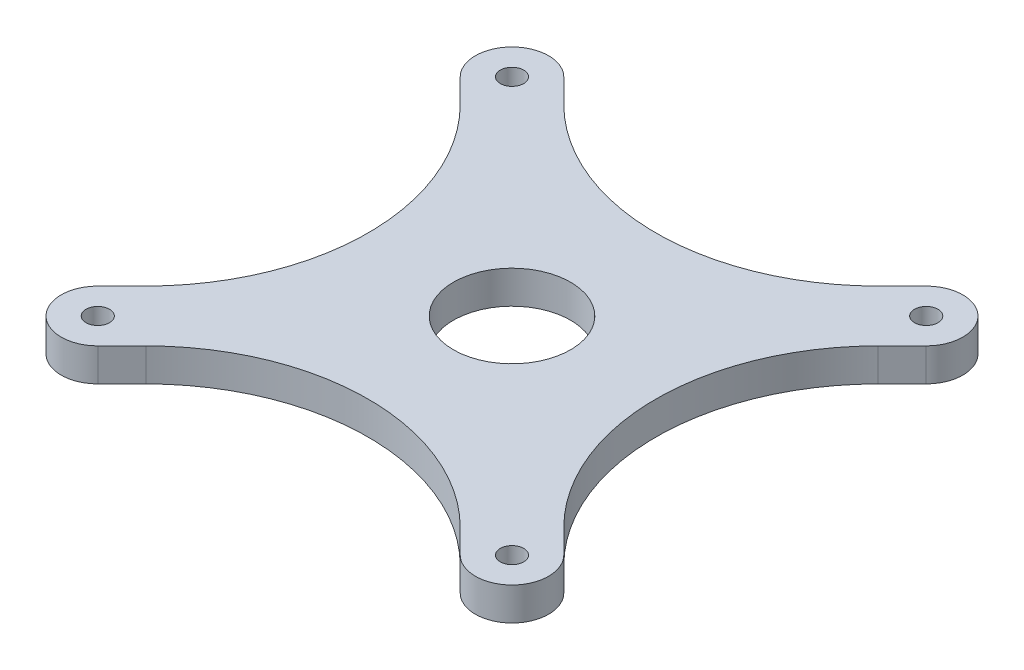
from build123d import *

# Parameters (mm, degrees)
SKETCH_1_W          = 70
SKETCH_1_H          = 70
EXTRUDE_1_DEPTH     = 5
SKETCH_2_R          = 8
CUT_EXTRUDE_1_DEPTH = 2.5
CUT_EXTRUDE_2_REACH = 4.5
SKETCH_3_R          = 6.5
SKETCH_4_W          = 70
SKETCH_4_H          = 70
SKETCH_4_R          = 10
CUT_EXTRUDE_3_DEPTH = 0.5
CUT_EXTRUDE_4_REACH = 7
SKETCH_5_R          = 1.6
CUT_EXTRUDE_6_REACH = 6.5
CUT_EXTRUDE_7_REACH = 6.5
FILLET_1_R          = 10
SKETCH_8_R          = 10
CUT_EXTRUDE_8_DEPTH = 0.5
EXTRUDE_2_DEPTH     = 4.5
CUT_EXTRUDE_9_REACH = 4
SKETCH_10_R         = 8
SKETCH_10_R_2       = 6.5


with BuildPart() as part:
    # 草图1 → 凸台-拉伸1 (new body)
    with BuildSketch(Plane(origin=(0, 0, 0), x_dir=(1, 0, 0), z_dir=(0, 1, 0))):
        Rectangle(SKETCH_1_W, SKETCH_1_H)
    extrude(amount=EXTRUDE_1_DEPTH)

    # 草图2 → 切除-拉伸1 (cut)
    with BuildSketch(Plane(origin=(0, 5, 0), x_dir=(1, 0, 0), z_dir=(0, 1, 0))):
        Circle(SKETCH_2_R)
    extrude(amount=-CUT_EXTRUDE_1_DEPTH, mode=Mode.SUBTRACT)

    # 草图3 → 切除-拉伸2 (cut, up to next)
    with BuildSketch(Plane(origin=(0, 2.5, 0), x_dir=(1, 0, 0), z_dir=(0, 1, 0)), mode=Mode.PRIVATE) as cut_extrude_2_sk1:
        Circle(SKETCH_3_R)
    cut_extrude_2_tool1 = extrude(cut_extrude_2_sk1.sketch, amount=-CUT_EXTRUDE_2_REACH, mode=Mode.PRIVATE) & part.part
    add(cut_extrude_2_tool1.solids().sort_by_distance((0, 2.5, 0))[0], mode=Mode.SUBTRACT)

    # 草图4 → 切除-拉伸3 (cut)
    with BuildSketch(Plane.XZ):
        Rectangle(SKETCH_4_W, SKETCH_4_H)
        Circle(SKETCH_4_R, mode=Mode.SUBTRACT)
    extrude(amount=-CUT_EXTRUDE_3_DEPTH, mode=Mode.SUBTRACT)

    # 草图5 → 切除-拉伸4 (cut, up to next)
    with BuildSketch(Plane(origin=(0, 5, 0), x_dir=(1, 0, 0), z_dir=(0, 1, 0)), mode=Mode.PRIVATE) as cut_extrude_4_sk1:
        with Locations((28.284271247, -28.284271247)):
            Circle(SKETCH_5_R)
    cut_extrude_4_tool1 = extrude(cut_extrude_4_sk1.sketch, amount=-CUT_EXTRUDE_4_REACH, mode=Mode.PRIVATE) & part.part
    add(cut_extrude_4_tool1.solids().sort_by_distance((28.284271, 5, 28.284271))[0], mode=Mode.SUBTRACT)
    # 草图5 → 切除-拉伸4 (cut, up to next)
    with BuildSketch(Plane(origin=(0, 5, 0), x_dir=(1, 0, 0), z_dir=(0, 1, 0)), mode=Mode.PRIVATE) as cut_extrude_4_sk2:
        with Locations((-28.284271247, -28.284271247)):
            Circle(SKETCH_5_R)
    cut_extrude_4_tool2 = extrude(cut_extrude_4_sk2.sketch, amount=-CUT_EXTRUDE_4_REACH, mode=Mode.PRIVATE) & part.part
    add(cut_extrude_4_tool2.solids().sort_by_distance((-28.284271, 5, 28.284271))[0], mode=Mode.SUBTRACT)
    # 草图5 → 切除-拉伸4 (cut, up to next)
    with BuildSketch(Plane(origin=(0, 5, 0), x_dir=(1, 0, 0), z_dir=(0, 1, 0)), mode=Mode.PRIVATE) as cut_extrude_4_sk3:
        with Locations((-28.284271247, 28.284271247)):
            Circle(SKETCH_5_R)
    cut_extrude_4_tool3 = extrude(cut_extrude_4_sk3.sketch, amount=-CUT_EXTRUDE_4_REACH, mode=Mode.PRIVATE) & part.part
    add(cut_extrude_4_tool3.solids().sort_by_distance((-28.284271, 5, -28.284271))[0], mode=Mode.SUBTRACT)
    # 草图5 → 切除-拉伸4 (cut, up to next)
    with BuildSketch(Plane(origin=(0, 5, 0), x_dir=(1, 0, 0), z_dir=(0, 1, 0)), mode=Mode.PRIVATE) as cut_extrude_4_sk4:
        with Locations((28.284271247, 28.284271247)):
            Circle(SKETCH_5_R)
    cut_extrude_4_tool4 = extrude(cut_extrude_4_sk4.sketch, amount=-CUT_EXTRUDE_4_REACH, mode=Mode.PRIVATE) & part.part
    add(cut_extrude_4_tool4.solids().sort_by_distance((28.284271, 5, -28.284271))[0], mode=Mode.SUBTRACT)

    # 草图6 → 切除-拉伸6 (cut, up to next)
    with BuildSketch(Plane.XZ.offset(-0.5), mode=Mode.PRIVATE) as cut_extrude_6_sk1:
        with BuildLine():
            Line((27.928932188, 35), (4.565391967, 11.636459779))
            ThreePointArc((4.565391967, 11.636459779), (0, 12.5), (-4.565391967, 11.636459779))
            Line((-4.565391967, 11.636459779), (-27.928932188, 35))
            Line((-27.928932188, 35), (27.928932188, 35))
        make_face()
    cut_extrude_6_tool1 = extrude(cut_extrude_6_sk1.sketch, amount=-CUT_EXTRUDE_6_REACH, mode=Mode.PRIVATE) & part.part
    add(cut_extrude_6_tool1.solids().sort_by_distance((0, 0.5, 26.217235))[0], mode=Mode.SUBTRACT)
    # 草图6 → 切除-拉伸6 (cut, up to next)
    with BuildSketch(Plane.XZ.offset(-0.5), mode=Mode.PRIVATE) as cut_extrude_6_sk2:
        with BuildLine():
            Line((35, -27.928932188), (11.636459779, -4.565391967))
            ThreePointArc((11.636459779, -4.565391967), (12.5, 0), (11.636459779, 4.565391967))
            Line((11.636459779, 4.565391967), (35, 27.928932188))
            Line((35, 27.928932188), (35, -27.928932188))
        make_face()
    cut_extrude_6_tool2 = extrude(cut_extrude_6_sk2.sketch, amount=-CUT_EXTRUDE_6_REACH, mode=Mode.PRIVATE) & part.part
    add(cut_extrude_6_tool2.solids().sort_by_distance((26.217235, 0.5, 0))[0], mode=Mode.SUBTRACT)
    # 草图6 → 切除-拉伸6 (cut, up to next)
    with BuildSketch(Plane.XZ.offset(-0.5), mode=Mode.PRIVATE) as cut_extrude_6_sk3:
        with BuildLine():
            Line((-27.928932188, -35), (-4.565391967, -11.636459779))
            ThreePointArc((-4.565391967, -11.636459779), (0, -12.5), (4.565391967, -11.636459779))
            Line((4.565391967, -11.636459779), (27.928932188, -35))
            Line((27.928932188, -35), (-27.928932188, -35))
        make_face()
    cut_extrude_6_tool3 = extrude(cut_extrude_6_sk3.sketch, amount=-CUT_EXTRUDE_6_REACH, mode=Mode.PRIVATE) & part.part
    add(cut_extrude_6_tool3.solids().sort_by_distance((0, 0.5, -26.217235))[0], mode=Mode.SUBTRACT)
    # 草图6 → 切除-拉伸6 (cut, up to next)
    with BuildSketch(Plane.XZ.offset(-0.5), mode=Mode.PRIVATE) as cut_extrude_6_sk4:
        with BuildLine():
            Line((-35, 27.928932188), (-11.636459779, 4.565391967))
            ThreePointArc((-11.636459779, 4.565391967), (-12.5, 0), (-11.636459779, -4.565391967))
            Line((-11.636459779, -4.565391967), (-35, -27.928932188))
            Line((-35, -27.928932188), (-35, 27.928932188))
        make_face()
    cut_extrude_6_tool4 = extrude(cut_extrude_6_sk4.sketch, amount=-CUT_EXTRUDE_6_REACH, mode=Mode.PRIVATE) & part.part
    add(cut_extrude_6_tool4.solids().sort_by_distance((-26.217235, 0.5, 0))[0], mode=Mode.SUBTRACT)

    # 草图7 → 切除-拉伸7 (cut, up to next)
    with BuildSketch(Plane.XZ.offset(-0.5), mode=Mode.PRIVATE) as cut_extrude_7_sk1:
        with BuildLine():
            Line((35, 27.928932188), (35, 35))
            Line((35, 35), (27.928932188, 35))
            Line((27.928932188, 35), (24.748737342, 31.819805153))
            ThreePointArc((24.748737342, 31.819805153), (31.819805153, 31.819805153), (31.819805153, 24.748737342))
            Line((31.819805153, 24.748737342), (35, 27.928932188))
        make_face()
    cut_extrude_7_tool1 = extrude(cut_extrude_7_sk1.sketch, amount=-CUT_EXTRUDE_7_REACH, mode=Mode.PRIVATE) & part.part
    add(cut_extrude_7_tool1.solids().sort_by_distance((32.243136, 0.5, 32.243136))[0], mode=Mode.SUBTRACT)
    # 草图7 → 切除-拉伸7 (cut, up to next)
    with BuildSketch(Plane.XZ.offset(-0.5), mode=Mode.PRIVATE) as cut_extrude_7_sk2:
        with BuildLine():
            Line((27.928932188, -35), (24.748737342, -31.819805153))
            ThreePointArc((24.748737342, -31.819805153), (31.819805153, -31.819805153), (31.819805153, -24.748737342))
            Line((31.819805153, -24.748737342), (35, -27.928932188))
            Line((35, -27.928932188), (35, -35))
            Line((35, -35), (27.928932188, -35))
        make_face()
    cut_extrude_7_tool2 = extrude(cut_extrude_7_sk2.sketch, amount=-CUT_EXTRUDE_7_REACH, mode=Mode.PRIVATE) & part.part
    add(cut_extrude_7_tool2.solids().sort_by_distance((32.243136, 0.5, -32.243136))[0], mode=Mode.SUBTRACT)
    # 草图7 → 切除-拉伸7 (cut, up to next)
    with BuildSketch(Plane.XZ.offset(-0.5), mode=Mode.PRIVATE) as cut_extrude_7_sk3:
        with BuildLine():
            Line((-35, -27.928932188), (-31.819805153, -24.748737342))
            ThreePointArc((-31.819805153, -24.748737342), (-31.819805153, -31.819805153), (-24.748737342, -31.819805153))
            Line((-24.748737342, -31.819805153), (-27.928932188, -35))
            Line((-27.928932188, -35), (-35, -35))
            Line((-35, -35), (-35, -27.928932188))
        make_face()
    cut_extrude_7_tool3 = extrude(cut_extrude_7_sk3.sketch, amount=-CUT_EXTRUDE_7_REACH, mode=Mode.PRIVATE) & part.part
    add(cut_extrude_7_tool3.solids().sort_by_distance((-32.243136, 0.5, -32.243136))[0], mode=Mode.SUBTRACT)
    # 草图7 → 切除-拉伸7 (cut, up to next)
    with BuildSketch(Plane.XZ.offset(-0.5), mode=Mode.PRIVATE) as cut_extrude_7_sk4:
        with BuildLine():
            Line((-27.928932188, 35), (-24.748737342, 31.819805153))
            ThreePointArc((-24.748737342, 31.819805153), (-31.819805153, 31.819805153), (-31.819805153, 24.748737342))
            Line((-31.819805153, 24.748737342), (-35, 27.928932188))
            Line((-35, 27.928932188), (-35, 35))
            Line((-35, 35), (-27.928932188, 35))
        make_face()
    cut_extrude_7_tool4 = extrude(cut_extrude_7_sk4.sketch, amount=-CUT_EXTRUDE_7_REACH, mode=Mode.PRIVATE) & part.part
    add(cut_extrude_7_tool4.solids().sort_by_distance((-32.243136, 0.5, 32.243136))[0], mode=Mode.SUBTRACT)

    # 圆角1
    fillet_1_edges = [part.edges().sort_by_distance(p)[0] for p in [
        (4.565391967, 2.75, 11.636459779),
        (-4.565391967, 2.75, 11.636459779),
        (11.636459779, 2.75, -4.565391967),
        (11.636459779, 2.75, 4.565391967),
        (-4.565391967, 2.75, -11.636459779),
        (4.565391967, 2.75, -11.636459779),
        (-11.636459779, 2.75, 4.565391967),
        (-11.636459779, 2.75, -4.565391967),
    ]]
    fillet(fillet_1_edges, radius=FILLET_1_R)

    # 草图8 → 切除-拉伸8 (cut)
    with BuildSketch(Plane.XZ):
        Circle(SKETCH_8_R)
    extrude(amount=-CUT_EXTRUDE_8_DEPTH, mode=Mode.SUBTRACT)

    # 草图9 → 凸台-拉伸2 (add)
    with BuildSketch(Plane.XZ.offset(-0.5)):
        with BuildLine():
            Line((8.32300732, 15.394075132), (21.464466094, 28.535533906))
            ThreePointArc((21.464466094, 28.535533906), (0, 19.644660941), (-21.464466094, 28.535533906))
            Line((-21.464466094, 28.535533906), (-8.32300732, 15.394075132))
            ThreePointArc((-8.32300732, 15.394075132), (-4.820160406, 13.123419354), (-0.695521949, 12.480634969))
            ThreePointArc((-0.695521949, 12.480634969), (0, 12.5), (0.695521949, 12.480634969))
            ThreePointArc((0.695521949, 12.480634969), (4.820160406, 13.123419354), (8.32300732, 15.394075132))
        make_face()
        with BuildLine():
            Line((28.535533906, 21.464466094), (15.394075132, 8.32300732))
            ThreePointArc((15.394075132, 8.32300732), (13.123419354, 4.820160406), (12.480634969, 0.695521949))
            ThreePointArc((12.480634969, 0.695521949), (12.5, 0), (12.480634969, -0.695521949))
            ThreePointArc((12.480634969, -0.695521949), (13.123419354, -4.820160406), (15.394075132, -8.32300732))
            Line((15.394075132, -8.32300732), (28.535533906, -21.464466094))
            ThreePointArc((28.535533906, -21.464466094), (19.644660941, 0), (28.535533906, 21.464466094))
        make_face()
        with BuildLine():
            Line((21.464466094, -28.535533906), (8.32300732, -15.394075132))
            ThreePointArc((8.32300732, -15.394075132), (4.820160406, -13.123419354), (0.695521949, -12.480634969))
            ThreePointArc((0.695521949, -12.480634969), (0, -12.5), (-0.695521949, -12.480634969))
            ThreePointArc((-0.695521949, -12.480634969), (-4.820160406, -13.123419354), (-8.32300732, -15.394075132))
            Line((-8.32300732, -15.394075132), (-21.464466094, -28.535533906))
            ThreePointArc((-21.464466094, -28.535533906), (0, -19.644660941), (21.464466094, -28.535533906))
        make_face()
        with BuildLine():
            Line((-28.535533906, -21.464466094), (-15.394075132, -8.32300732))
            ThreePointArc((-15.394075132, -8.32300732), (-13.123419354, -4.820160406), (-12.480634969, -0.695521949))
            ThreePointArc((-12.480634969, -0.695521949), (-12.5, 0), (-12.480634969, 0.695521949))
            ThreePointArc((-12.480634969, 0.695521949), (-13.123419354, 4.820160406), (-15.394075132, 8.32300732))
            Line((-15.394075132, 8.32300732), (-28.535533906, 21.464466094))
            ThreePointArc((-28.535533906, 21.464466094), (-19.644660941, 0), (-28.535533906, -21.464466094))
        make_face()
    extrude(amount=-EXTRUDE_2_DEPTH)

    # 草图10 → 切除-拉伸9 (cut, up to next)
    with BuildSketch(Plane(origin=(0, 2.5, 0), x_dir=(1, 0, 0), z_dir=(0, 1, 0)), mode=Mode.PRIVATE) as cut_extrude_9_sk1:
        Circle(SKETCH_10_R)
        Circle(SKETCH_10_R_2, mode=Mode.SUBTRACT)
    cut_extrude_9_tool1 = extrude(cut_extrude_9_sk1.sketch, amount=-CUT_EXTRUDE_9_REACH, mode=Mode.PRIVATE) & part.part
    add(cut_extrude_9_tool1.solids().sort_by_distance((-7.773726, 2.5, 0))[0], mode=Mode.SUBTRACT)


solid = part.part
